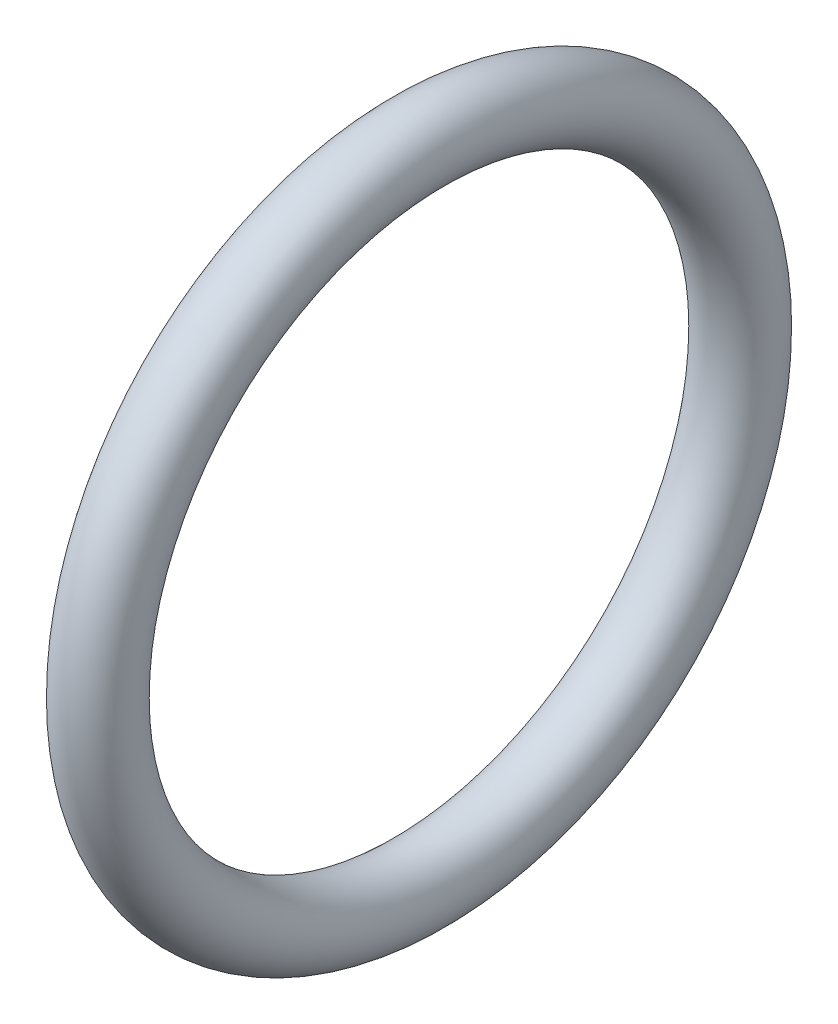
from build123d import *

# Parameters (mm, degrees)
SKETCH2_R = 0.762


with BuildPart() as part:
    # Sketch2 → Revolve3 (revolve)
    with BuildSketch(Plane.XY, mode=Mode.PRIVATE) as revolve3_sk:
        with Locations((2.54, -6.731)):
            Circle(SKETCH2_R)
    revolve(revolve3_sk.sketch.rotate(Axis((-34.684965636, 0, 0), (1, 0, 0)), 270), axis=Axis((-34.684965636, 0, 0), (1, 0, 0)))  # turned: the seam where the file's is


solid = part.part
